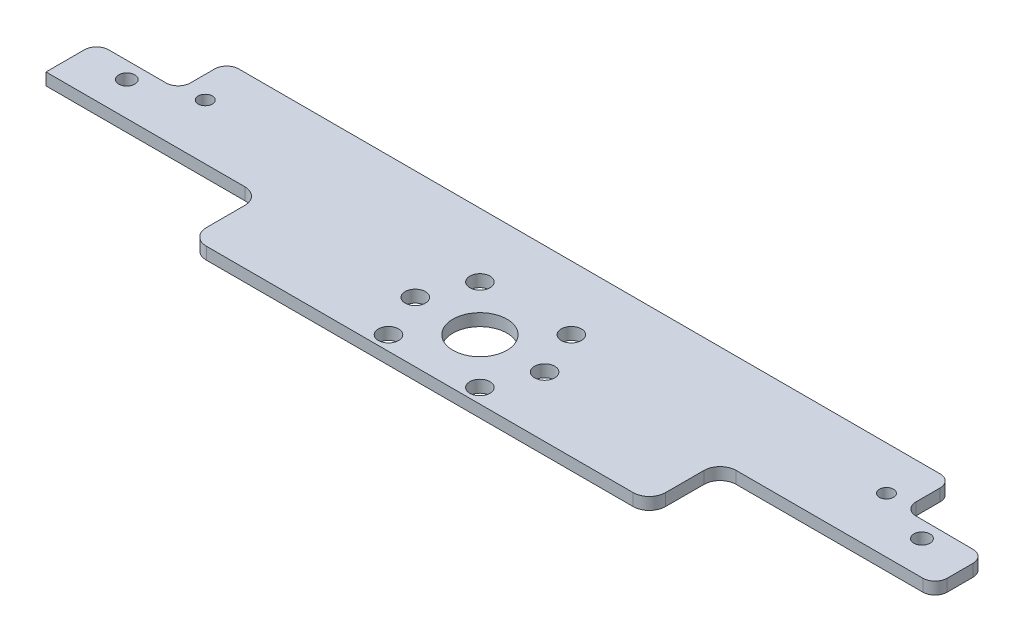
from build123d import *

# Parameters (mm, degrees)
SKETCH_2_R      = 2.5
SKETCH_2_R_2    = 2.499999999
SKETCH_2_R_3    = 6.682030953
SKETCH_2_R_4    = 2
SKETCH_2_R_5    = 1.75
EXTRUDE_1_DEPTH = 3
FILLET_1_R      = 4
FILLET_2_R      = 3


with BuildPart() as part:
    # 草图2 → 凸台-拉伸1 (new body)
    with BuildSketch(Plane(origin=(0, 0, 0), x_dir=(1, 0, 0), z_dir=(0, 1, 0))):
        Polygon((56.805521657, -9.129480985), (110, -9.129480985), (110, 3.251695679), (89.78, 3.370519015), (89.78, 15.370519015), (-89.78, 15.370519015), (-89.78, 3.370519015), (-110, 3.370519015), (-110, -9.129480985), (-56.805521657, -9.129480985), (-56.805521657, -26.629480985), (56.805521657, -26.629480985), align=None)
        with Locations((-16.000000001, -11.748304322)):
            Circle(SKETCH_2_R, mode=Mode.SUBTRACT)
        with Locations((-11.313708499, -23.062012821)):
            Circle(SKETCH_2_R_2, mode=Mode.SUBTRACT)
        with Locations((-11.3137085, -0.434595823)):
            Circle(SKETCH_2_R, mode=Mode.SUBTRACT)
        with Locations((0, -11.748304321)):
            Circle(SKETCH_2_R_3, mode=Mode.SUBTRACT)
        with Locations((11.313708498, -0.434595822)):
            Circle(SKETCH_2_R, mode=Mode.SUBTRACT)
        with Locations((16, -11.748304321)):
            Circle(SKETCH_2_R, mode=Mode.SUBTRACT)
        with Locations((11.313708499, -23.062012821)):
            Circle(SKETCH_2_R_2, mode=Mode.SUBTRACT)
        with Locations((98.383175919, -0.748304322)):
            Circle(SKETCH_2_R_4, mode=Mode.SUBTRACT)
        with Locations((84.28, 4.561107346)):
            Circle(SKETCH_2_R_5, mode=Mode.SUBTRACT)
        with Locations((-84.280000001, 4.561107346)):
            Circle(SKETCH_2_R_5, mode=Mode.SUBTRACT)
        with Locations((-98.38317592, -0.748304322)):
            Circle(SKETCH_2_R_4, mode=Mode.SUBTRACT)
    extrude(amount=EXTRUDE_1_DEPTH)

    # 圆角1
    fillet_1_edges = [part.edges().sort_by_distance(p)[0] for p in [
        (56.805521657, 1.5, 9.129480985),
        (56.805521657, 1.5, 26.629480985),
        (-56.805521657, 1.5, 26.629480985),
        (-56.805521657, 1.5, 9.129480985),
    ]]
    fillet(fillet_1_edges, radius=FILLET_1_R)

    # 圆角2
    fillet_2_edges = [part.edges().sort_by_distance(p)[0] for p in [
        (89.78, 1.5, -3.370519015),
        (110, 1.5, -3.251695679),
        (110, 1.5, 9.129480985),
        (-110, 1.5, -3.370519015),
        (-89.78, 1.5, -3.370519015),
        (-89.78, 1.5, -15.370519015),
        (89.78, 1.5, -15.370519015),
    ]]
    fillet(fillet_2_edges, radius=FILLET_2_R)


solid = part.part
